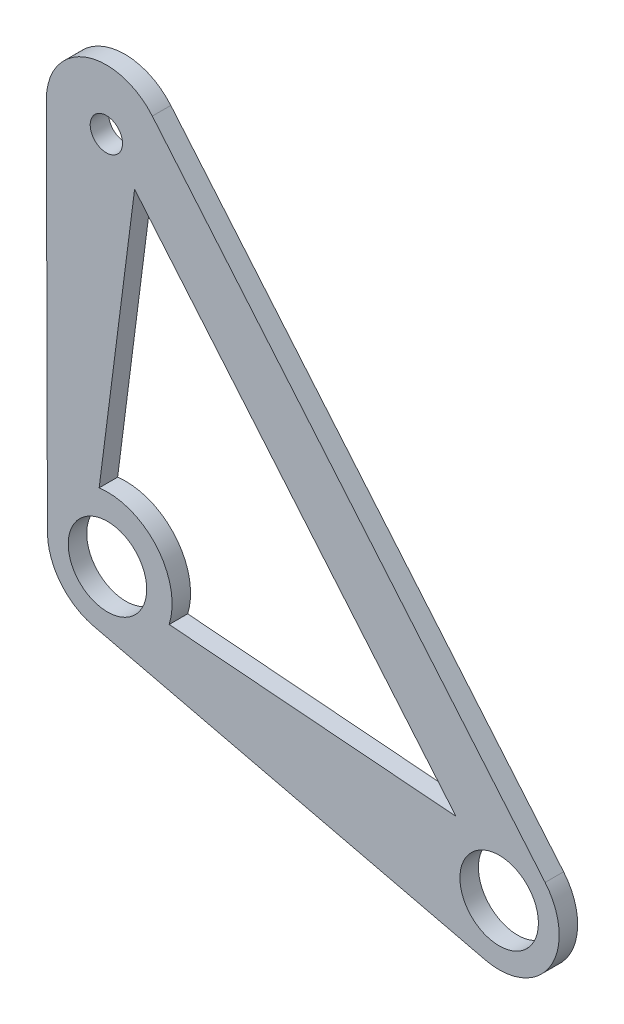
from build123d import *

# Parameters (mm, degrees)
SKETCH_1_R          = 6.5
SKETCH_1_R_2        = 1.75
SKETCH_1_R_3        = 4.25
EXTRUDE_1_DEPTH     = 2
SKETCH_2_R          = 4.25
CUT_EXTRUDE_1_DEPTH = 3


with BuildPart() as part:
    # 草图1 → 凸台-拉伸1 (new body)
    with BuildSketch(Plane.XY):
        with BuildLine():
            Line((-6.617803136, 40.4809175), (-6.49997249, -0.018911091))
            ThreePointArc((-6.49997249, -0.018911091), (-0.009455556, 6.499993122), (6.5, 0))
            ThreePointArc((6.5, 0), (4.028885042, -5.100792617), (-1.505564714, -6.323232946))
            Line((-1.505564714, -6.323232946), (40.908736278, -16.422097799))
            ThreePointArc((40.908736278, -16.422097799), (36.882334136, -6.68604451), (47.389966762, -5.916431333))
            Line((47.389966762, -5.916431333), (4.857835124, 44.682262111))
            ThreePointArc((4.857835124, 44.682262111), (5.989207405, 42.725606264), (6.382169354, 40.499828591))
            ThreePointArc((6.382169354, 40.499828591), (-0.10837509, 33.999835469), (-6.617803136, 40.4809175))
        make_face()
        with Locations((-0.117830646, 40.499828591)):
            Circle(SKETCH_1_R)
        with Locations((-0.117830646, 40.499828591)):
            Circle(SKETCH_1_R_2, mode=Mode.SUBTRACT)
        with BuildLine():
            ThreePointArc((6.5, 0), (-0.009455556, 6.499993122), (-6.49997249, -0.018911091))
            ThreePointArc((-6.49997249, -0.018911091), (-5.094926397, -4.036300906), (-1.505564714, -6.323232946))
            ThreePointArc((-1.505564714, -6.323232946), (4.028885042, -5.100792617), (6.5, 0))
        make_face()
        Circle(SKETCH_1_R_3, mode=Mode.SUBTRACT)
        with Locations((42.414300993, -10.098864853)):
            Circle(SKETCH_1_R)
        with Locations((42.414300993, -10.098864853)):
            Circle(SKETCH_1_R_3, mode=Mode.SUBTRACT)
    extrude(amount=EXTRUDE_1_DEPTH)

    # 草图2 → 切除-拉伸1 (cut, through all)
    with BuildSketch(Plane.XY.offset(2)):
        with Locations((42.414300993, -10.098864853)):
            Circle(SKETCH_2_R)
        with BuildLine():
            Line((2.93856308, 36.863765144), (37.74927899, -4.549083802))
            Line((37.74927899, -4.549083802), (6.683866701, -2.079886036))
            ThreePointArc((6.683866701, -2.079886036), (5.358409291, 4.504159175), (-0.899681346, 6.941943062))
            Line((-0.899681346, 6.941943062), (2.93856308, 36.863765144))
        make_face()
    extrude(amount=-CUT_EXTRUDE_1_DEPTH, mode=Mode.SUBTRACT)


solid = part.part
